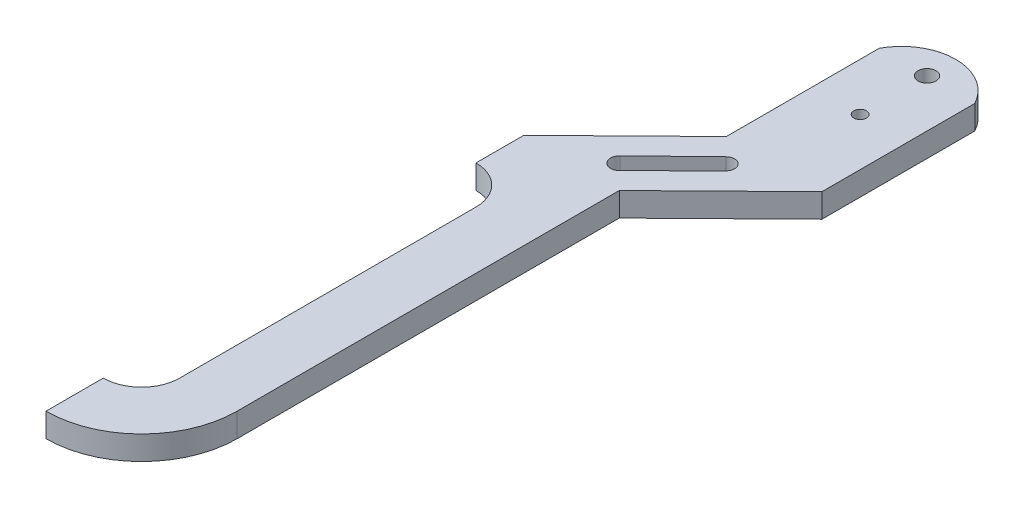
from build123d import *

# Parameters (mm, degrees)
SKETCH1_R           = 1.190625
SKETCH1_R_2         = 0.840105
BOSS_EXTRUDE1_DEPTH = 3.175


with BuildPart() as part:
    # Sketch1 → Boss-Extrude1 (new body)
    with BuildSketch(Plane(origin=(0, 0, 0), x_dir=(1, 0, 0), z_dir=(0, 1, 0))):
        with BuildLine():
            Line((-0.904421156, -38.735), (-0.904421156, -89.535))
            ThreePointArc((-0.904421156, -89.535), (-4.624165035, -98.515256121), (-13.604421156, -102.235))
            Line((-13.604421156, -102.235), (-13.604421156, -94.615))
            ThreePointArc((-13.604421156, -94.615), (-10.012318708, -93.127102448), (-8.524421156, -89.535))
            Line((-8.524421156, -89.535), (-8.524421156, -50.165))
            ThreePointArc((-8.524421156, -50.165), (-10.012318708, -46.572897552), (-13.604421156, -45.085))
            Line((-13.604421156, -45.085), (-13.604421156, -38.735))
            Line((-13.604421156, -38.735), (0, -25.4))
            Line((0, -25.4), (0, -5.08))
            ThreePointArc((0, -5.08), (2.647345547, -2.295575911), (6.35, -1.27))
            ThreePointArc((6.35, -1.27), (10.052654453, -2.295575911), (12.7, -5.08))
            Line((12.7, -5.08), (12.7, -25.4))
            Line((12.7, -25.4), (-0.904421156, -38.735))
        make_face()
        with Locations((6.35, -5.08)):
            Circle(SKETCH1_R, mode=Mode.SUBTRACT)
        with Locations((6.35, -13.97)):
            Circle(SKETCH1_R_2, mode=Mode.SUBTRACT)
        with BuildLine():
            Line((-3.170272283, -36.423369478), (3.917065977, -29.396206618))
            ThreePointArc((3.917065977, -29.396206618), (3.933341902, -27.768784902), (2.305920187, -27.752508977))
            Line((2.305920187, -27.752508977), (-4.856606356, -34.693063118))
            ThreePointArc((-4.856606356, -34.693063118), (-4.881077896, -36.403805569), (-3.170272283, -36.423369478))
        make_face(mode=Mode.SUBTRACT)
    extrude(amount=BOSS_EXTRUDE1_DEPTH)


solid = part.part
